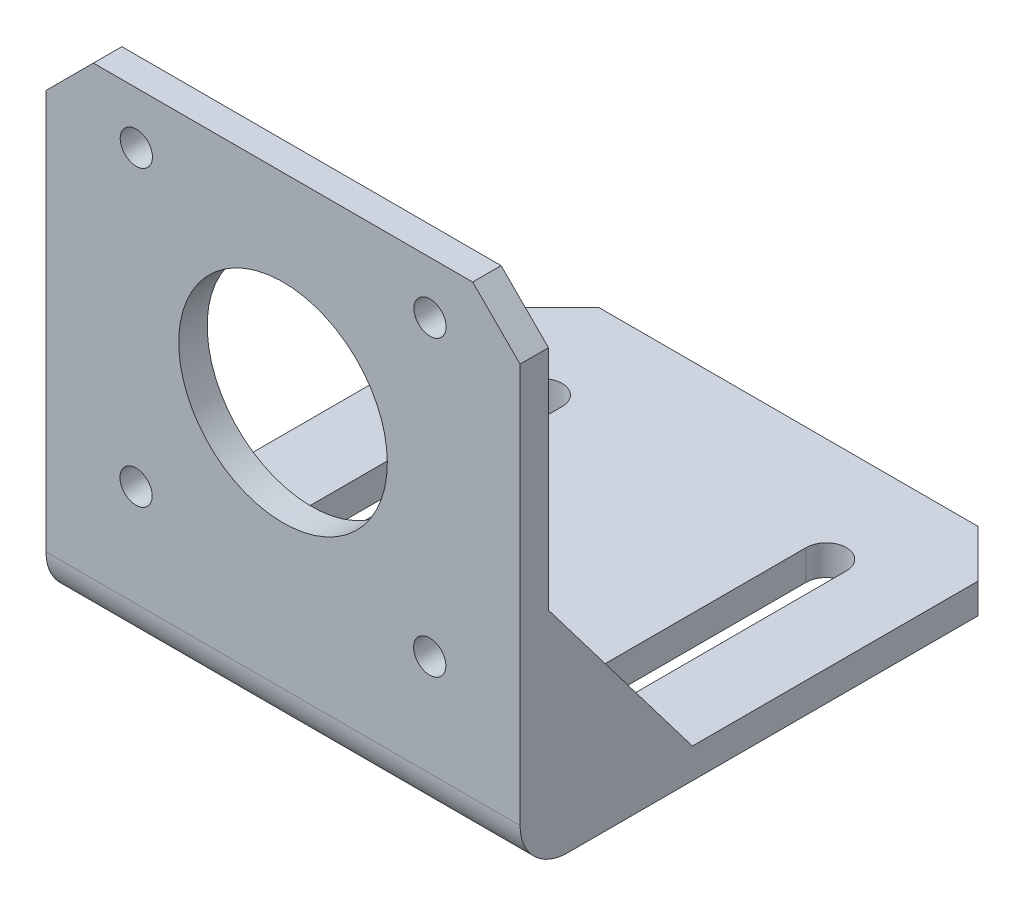
from build123d import *

# Parameters (mm, degrees)
SKETCH1_W           = 50
SKETCH1_H           = 53.3
BOSS_EXTRUDE1_DEPTH = 3.175
SKETCH2_W           = 50
SKETCH2_H           = 3
BOSS_EXTRUDE2_DEPTH = 48.97
SKETCH3_W           = 3.175
SKETCH3_H           = 15
SKETCH3_H_2         = 15.175
BOSS_EXTRUDE3_DEPTH = 20
CUT_EXTRUDE1_DEPTH  = 65
SKETCH5_R           = 11
SKETCH5_R_2         = 1.7
CUT_EXTRUDE2_DEPTH  = 65
CUT_EXTRUDE3_DEPTH  = 65
CHAMFER1_SIZE       = 5
FILLET1_R           = 5


with BuildPart() as part:
    # Sketch1 → Boss-Extrude1 (new body)
    with BuildSketch(Plane(origin=(0, 0, 0), x_dir=(1, 0, 0), z_dir=(0, 1, 0))):
        with Locations((25, 26.65)):
            Rectangle(SKETCH1_W, SKETCH1_H)
    extrude(amount=BOSS_EXTRUDE1_DEPTH)

    # Sketch2 → Boss-Extrude2 (add)
    with BuildSketch(Plane(origin=(0, 3.175, 0), x_dir=(1, 0, 0), z_dir=(0, 1, 0))):
        with Locations((25, 1.5)):
            Rectangle(SKETCH2_W, SKETCH2_H)
    extrude(amount=BOSS_EXTRUDE2_DEPTH)

    # Sketch3 → Boss-Extrude3 (add)
    with BuildSketch(Plane(origin=(0, 3.175, 0), x_dir=(1, 0, 0), z_dir=(0, 1, 0))):
        with Locations((1.5875, 10.5)):
            Rectangle(SKETCH3_W, SKETCH3_H)
        with Locations((48.4125, 10.5875)):
            Rectangle(SKETCH3_W, SKETCH3_H_2)
    extrude(amount=BOSS_EXTRUDE3_DEPTH)

    # Sketch4 → Cut-Extrude1 (cut)
    with BuildSketch(Plane(origin=(50, 0, 0), x_dir=(0, 0, -1), z_dir=(1, 0, 0))):
        Polygon((18.175, 3.175), (3, 23.175), (18.175, 23.175), align=None)
    extrude(amount=-CUT_EXTRUDE1_DEPTH, mode=Mode.SUBTRACT)

    # Sketch5 → Cut-Extrude2 (cut)
    with BuildSketch(Plane.XY):
        with Locations((25, 31.145)):
            Circle(SKETCH5_R)
        with Locations((40.502, 46.647)):
            Circle(SKETCH5_R_2)
        with Locations((9.528, 46.677)):
            Circle(SKETCH5_R_2)
        with Locations((9.498, 15.703)):
            Circle(SKETCH5_R_2)
        with Locations((40.472, 15.673)):
            Circle(SKETCH5_R_2)
    extrude(amount=-CUT_EXTRUDE2_DEPTH, mode=Mode.SUBTRACT)

    # Sketch6 → Cut-Extrude3 (cut)
    with BuildSketch(Plane(origin=(0, 3.175, 0), x_dir=(1, 0, 0), z_dir=(0, 1, 0))):
        with BuildLine():
            ThreePointArc((42.125, 42.3), (40, 44.425), (37.875, 42.3))
            Line((37.875, 42.3), (37.875, 12.3))
            ThreePointArc((37.875, 12.3), (40, 10.175), (42.125, 12.3))
            Line((42.125, 12.3), (42.125, 42.3))
        make_face()
        with BuildLine():
            Line((7.875, 42.3), (7.875, 12.3))
            ThreePointArc((7.875, 12.3), (10, 10.175), (12.125, 12.3))
            Line((12.125, 12.3), (12.125, 42.3))
            ThreePointArc((12.125, 42.3), (10, 44.425), (7.875, 42.3))
        make_face()
    extrude(amount=-CUT_EXTRUDE3_DEPTH, mode=Mode.SUBTRACT)

    # Chamfer1
    chamfer1_edges = [part.edges().sort_by_distance(p)[0] for p in [
        (0, 1.5875, -53.3),
        (50, 1.5875, -53.3),
        (0, 52.145, -1.5),
        (50, 52.145, -1.5),
    ]]
    chamfer(chamfer1_edges, length=CHAMFER1_SIZE)

    # Fillet1
    fillet1_edges = [part.edges().sort_by_distance(p)[0] for p in [
        (25, 3.175, -3),
        (25, 0, 0),
    ]]
    fillet(fillet1_edges, radius=FILLET1_R)


solid = part.part
